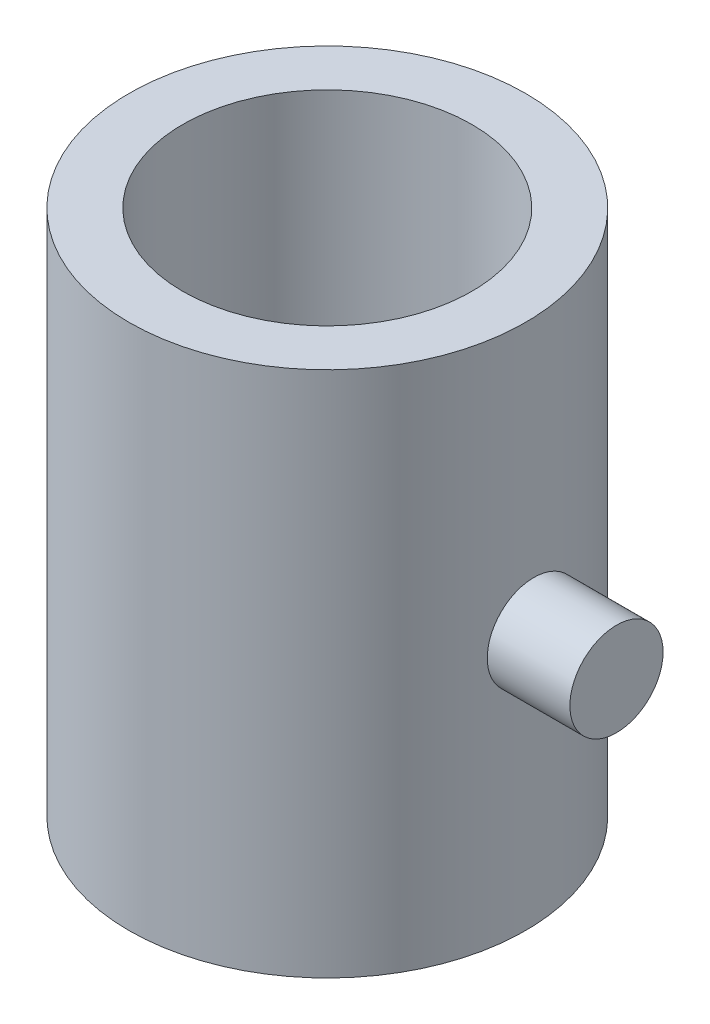
from build123d import *

# Parameters (mm, degrees)
SKETCH1_R           = 4.8
SKETCH1_R_2         = 3.5
BOSS_EXTRUDE1_DEPTH = 6.375
BOSS_EXTRUDE2_START = 5
SKETCH2_R           = 1.128123291
BOSS_EXTRUDE2_DEPTH = 2


with BuildPart() as part:
    # Sketch1 → Boss-Extrude1 (new body, symmetric)
    with BuildSketch(Plane(origin=(0, 0, 0), x_dir=(1, 0, 0), z_dir=(0, 1, 0))):
        Circle(SKETCH1_R)
        Circle(SKETCH1_R_2, mode=Mode.SUBTRACT)
    extrude(amount=BOSS_EXTRUDE1_DEPTH, both=True)


with BuildPart() as body_2:
    # Sketch2 → Boss-Extrude2 (new body)
    with BuildSketch(Plane(origin=(0, 0, 0), x_dir=(0, 0, -1), z_dir=(1, 0, 0)).offset(BOSS_EXTRUDE2_START)):
        Circle(SKETCH2_R)
    extrude(amount=BOSS_EXTRUDE2_DEPTH)


solid = Compound([part.part, body_2.part])
